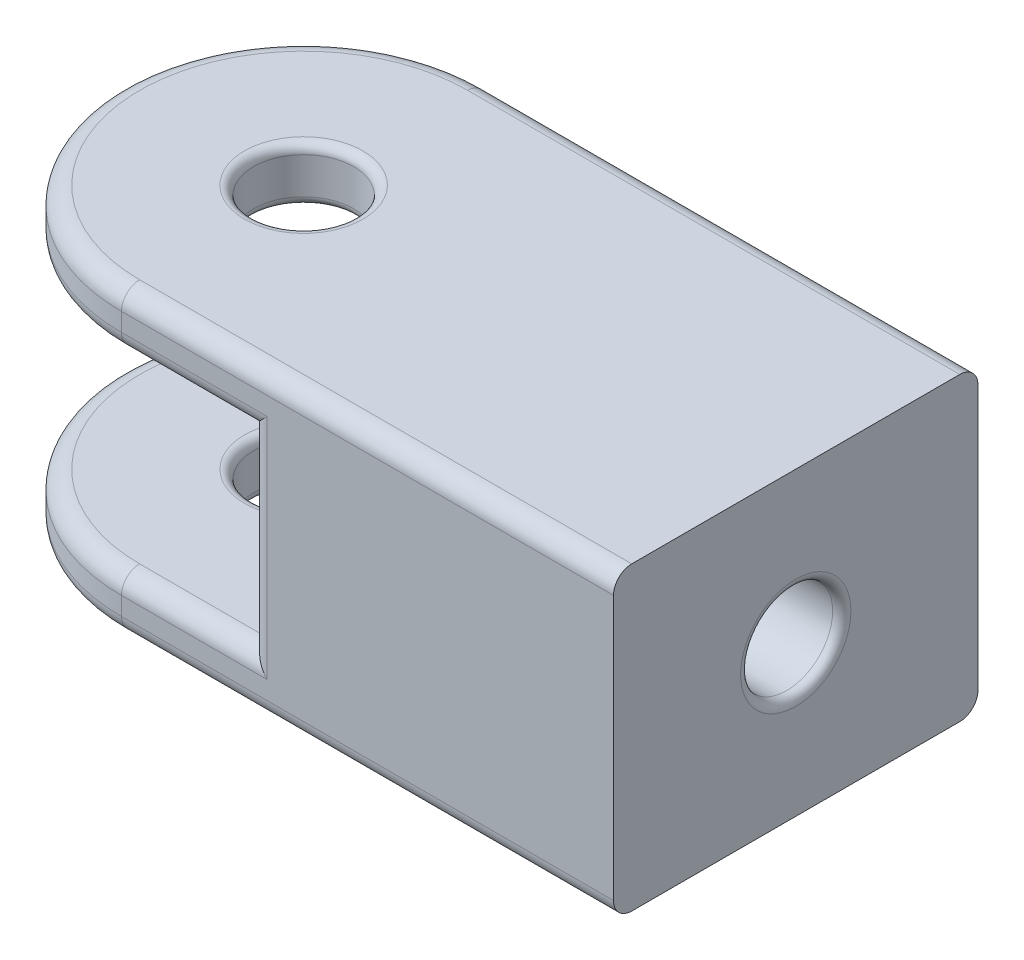
from build123d import *

# Parameters (mm, degrees)
SKETCH2_R           = 2.75
BOSS_EXTRUDE1_DEPTH = 3
SKETCH3_W           = 20
SKETCH3_H           = 13.5
BOSS_EXTRUDE2_DEPTH = 3
SKETCH4_R           = 2.75
BOSS_EXTRUDE3_DEPTH = 3
SKETCH5_W           = 20
SKETCH5_H           = 16.5
BOSS_EXTRUDE4_DEPTH = 17
SKETCH6_R           = 2.525
CUT_EXTRUDE1_DEPTH  = 17
FILLET1_R           = 1
FILLET2_R           = 0.5


with BuildPart() as part:
    # Sketch2 → Boss-Extrude1 (new body)
    with BuildSketch(Plane(origin=(0, 0, 0), x_dir=(1, 0, 0), z_dir=(0, 1, 0))):
        with BuildLine():
            Line((0, 10), (10, 10))
            Line((10, 10), (10, -10))
            Line((10, -10), (0, -10))
            ThreePointArc((0, -10), (-10, 0), (0, 10))
        make_face()
        Circle(SKETCH2_R, mode=Mode.SUBTRACT)
    extrude(amount=-BOSS_EXTRUDE1_DEPTH)

    # Sketch3 → Boss-Extrude2 (add)
    with BuildSketch(Plane(origin=(10, 0, 0), x_dir=(0, 0, -1), z_dir=(1, 0, 0))):
        with Locations((0, -6.75)):
            Rectangle(SKETCH3_W, SKETCH3_H)
    extrude(amount=-BOSS_EXTRUDE2_DEPTH)

    # Sketch4 → Boss-Extrude3 (add)
    with BuildSketch(Plane.XZ.offset(13.5)):
        with BuildLine():
            Line((0, -10), (10, -10))
            Line((10, -10), (10, 10))
            Line((10, 10), (0, 10))
            ThreePointArc((0, 10), (-10, 0), (0, -10))
        make_face()
        Circle(SKETCH4_R, mode=Mode.SUBTRACT)
    extrude(amount=BOSS_EXTRUDE3_DEPTH)

    # Sketch5 → Boss-Extrude4 (add)
    with BuildSketch(Plane(origin=(10, 0, 0), x_dir=(0, 0, -1), z_dir=(1, 0, 0))):
        with Locations((0, -8.25)):
            Rectangle(SKETCH5_W, SKETCH5_H)
    extrude(amount=BOSS_EXTRUDE4_DEPTH)

    # Sketch6 → Cut-Extrude1 (cut)
    with BuildSketch(Plane(origin=(27, 0, 0), x_dir=(0, 0, -1), z_dir=(1, 0, 0))):
        with Locations((0, -8.25)):
            Circle(SKETCH6_R)
    extrude(amount=-CUT_EXTRUDE1_DEPTH, mode=Mode.SUBTRACT)

    # Fillet1
    fillet1_edges = [part.edges().sort_by_distance(p)[0] for p in [
        (3.5, -3, -10),
        (7, -8.25, 10),
        (7, -8.25, -10),
        (13.5, -16.5, 10),
        (-10, -16.5, 0),
        (13.5, -16.5, -10),
        (3.5, -13.5, 10),
        (-10, -13.5, 0),
        (3.5, -13.5, -10),
        (-10, -3, 0),
        (13.5, 0, -10),
        (13.5, 0, 10),
        (-10, 0, 0),
        (3.5, -3, 10),
    ]]
    fillet(fillet1_edges, radius=FILLET1_R)

    # Fillet2
    fillet2_edges = [part.edges().sort_by_distance(p)[0] for p in [
        (-2.75, -3, 0),
        (-2.75, 0, 0),
        (-2.75, -13.5, 0),
        (-2.75, -16.5, 0),
        (27, -8.25, 2.525),
        (10, -8.25, 2.525),
    ]]
    fillet(fillet2_edges, radius=FILLET2_R)


solid = part.part
